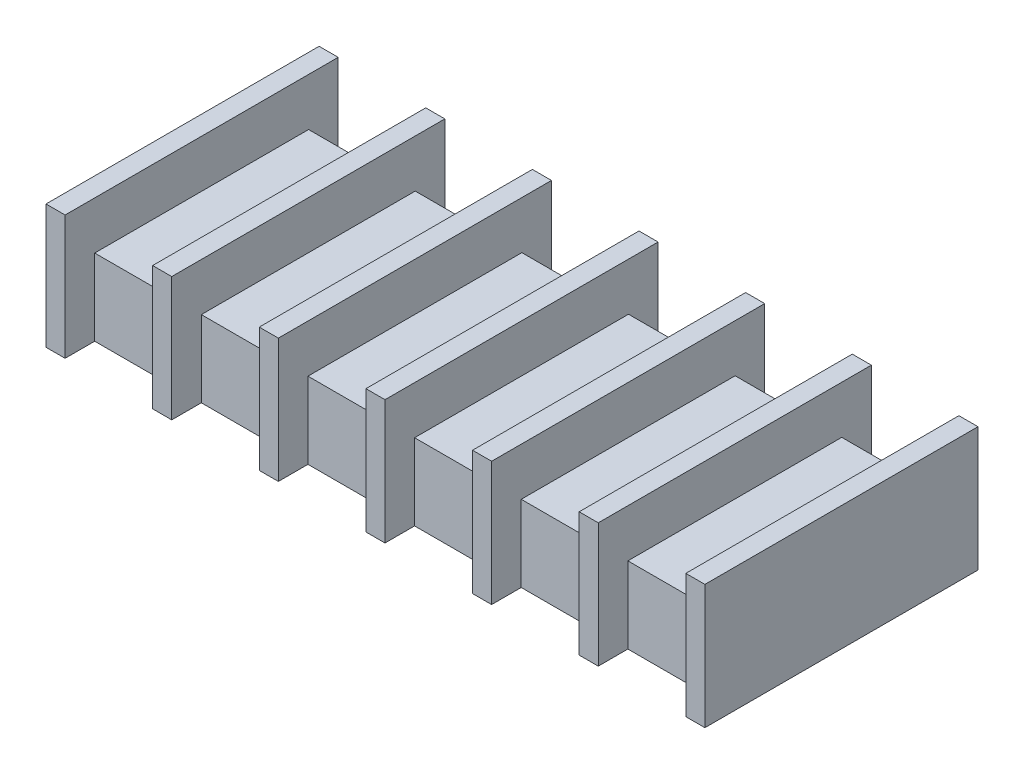
from build123d import *

# Parameters (mm, degrees)
BOSS_EXTRUDE1_DEPTH = 8
SKETCH2_W           = 2
SKETCH2_H           = 28.6
BOSS_EXTRUDE2_DEPTH = 13


with BuildPart() as part:
    # Sketch1 → Boss-Extrude1 (new body)
    with BuildSketch(Plane(origin=(0, 0, 0), x_dir=(1, 0, 0), z_dir=(0, 1, 0))):
        with BuildLine():
            Line((-33.5, 11.2), (33.5, 11.2))
            ThreePointArc((33.5, 11.2), (34.207106781, 10.907106781), (34.5, 10.2))
            Line((34.5, 10.2), (34.5, -10.2))
            ThreePointArc((34.5, -10.2), (34.207106781, -10.907106781), (33.5, -11.2))
            Line((33.5, -11.2), (-33.5, -11.2))
            ThreePointArc((-33.5, -11.2), (-34.207106781, -10.907106781), (-34.5, -10.2))
            Line((-34.5, -10.2), (-34.5, 10.2))
            ThreePointArc((-34.5, 10.2), (-34.207106781, 10.907106781), (-33.5, 11.2))
        make_face()
    extrude(amount=BOSS_EXTRUDE1_DEPTH)

    # Sketch2 → Boss-Extrude2 (add)
    with BuildSketch(Plane(origin=(0, 0, 0), x_dir=(1, 0, 0), z_dir=(0, 1, 0))):
        with Locations((-33.5, 0)):
            Rectangle(SKETCH2_W, SKETCH2_H)
        with Locations((-22.333333333, 0)):
            Rectangle(SKETCH2_W, SKETCH2_H)
        with Locations((-11.166666667, 0)):
            Rectangle(SKETCH2_W, SKETCH2_H)
        Rectangle(SKETCH2_W, SKETCH2_H)
        with Locations((11.166666667, 0)):
            Rectangle(SKETCH2_W, SKETCH2_H)
        with Locations((22.333333333, 0)):
            Rectangle(SKETCH2_W, SKETCH2_H)
        with Locations((33.5, 0)):
            Rectangle(SKETCH2_W, SKETCH2_H)
    extrude(amount=BOSS_EXTRUDE2_DEPTH)


solid = part.part
